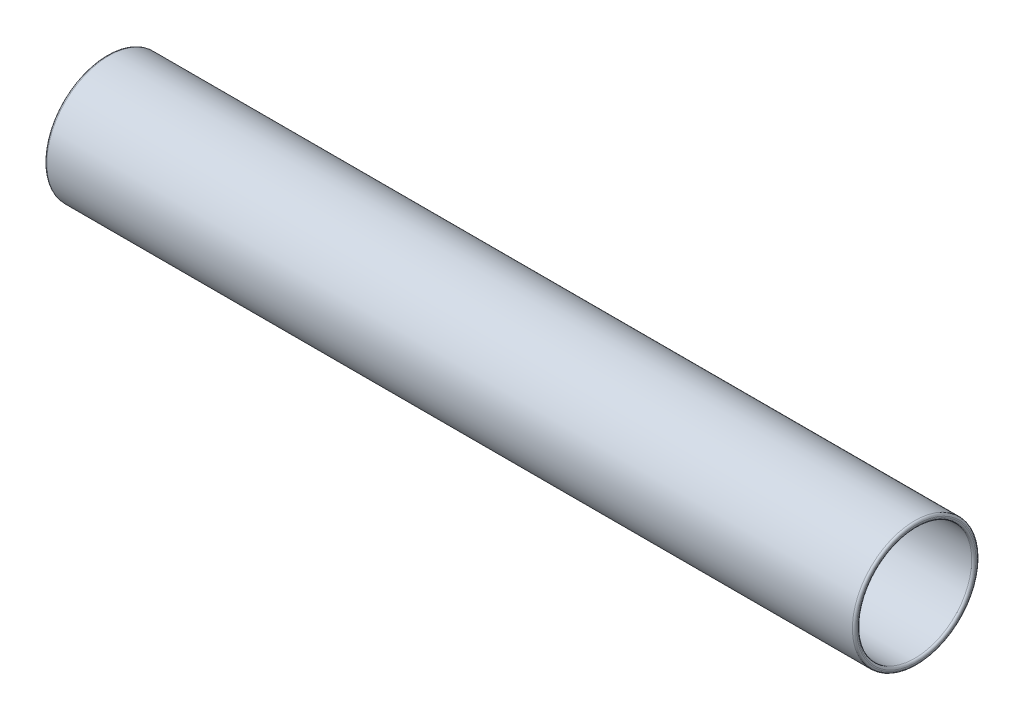
from build123d import *

# Parameters (mm, degrees)
SKETCH1_R           = 57.75
SKETCH1_R_2         = 52.75
BOSS_EXTRUDE1_DEPTH = 750
FILLET1_R           = 2
FILLET2_R           = 2


with BuildPart() as part:
    # Sketch1 → Boss-Extrude1 (new body)
    with BuildSketch(Plane(origin=(0, 0, 0), x_dir=(0, 0, -1), z_dir=(1, 0, 0))):
        Circle(SKETCH1_R)
        Circle(SKETCH1_R_2, mode=Mode.SUBTRACT)
    extrude(amount=BOSS_EXTRUDE1_DEPTH)

    # Fillet1
    fillet1_edges = [part.edges().sort_by_distance(p)[0] for p in [
        (750, 0, 57.75),
        (750, 0, 52.75),
    ]]
    fillet(fillet1_edges, radius=FILLET1_R)

    # Fillet2
    fillet2_edges = [part.edges().sort_by_distance(p)[0] for p in [
        (0, 0, 57.75),
        (0, 0, 52.75),
    ]]
    fillet(fillet2_edges, radius=FILLET2_R)


solid = part.part
